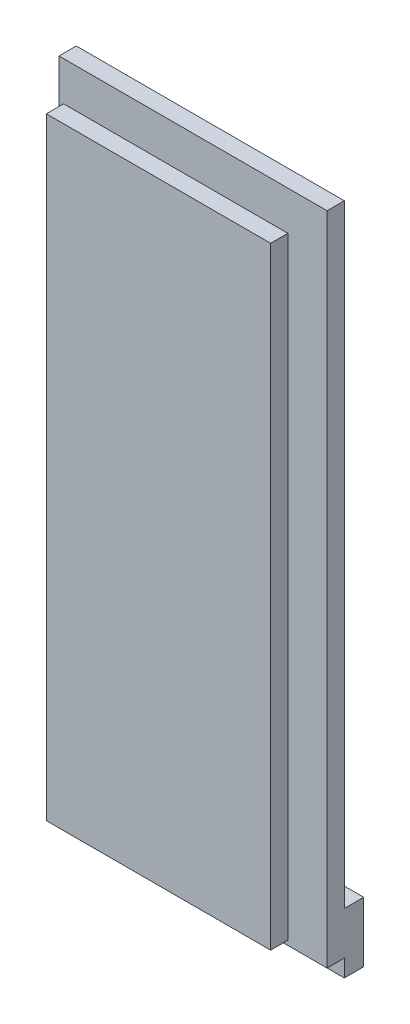
from build123d import *

# Parameters (mm, degrees)
SKETCH2_W      = 31.1404
SKETCH2_H      = 76.2
EXTRUDE1_DEPTH = 2.0066
SKETCH3_W      = 22.0472
SKETCH3_H      = 67.1068
EXTRUDE2_DEPTH = 2.0066
SKETCH4_W      = 26.0604
SKETCH4_H      = 71.12
EXTRUDE3_DEPTH = 2.0066
SKETCH5_W      = 31.1404
SKETCH5_H      = 7
EXTRUDE4_DEPTH = 2.25


with BuildPart() as part:
    # Sketch2 → Extrude1 (new body)
    with BuildSketch(Plane.XY):
        Rectangle(SKETCH2_W, SKETCH2_H)
    extrude(amount=EXTRUDE1_DEPTH)

    # Sketch3 → Extrude2 (add)
    with BuildSketch(Plane.XY.offset(2.0066)):
        Rectangle(SKETCH3_W, SKETCH3_H)
    extrude(amount=EXTRUDE2_DEPTH)

    # Sketch4 → Extrude3 (add)
    with BuildSketch(Plane.XY.offset(4.0132)):
        Rectangle(SKETCH4_W, SKETCH4_H)
    extrude(amount=EXTRUDE3_DEPTH)

    # Sketch5 → Extrude4 (add)
    with BuildSketch(Plane(origin=(0, 0, 0), x_dir=(-1, 0, 0), z_dir=(0, 0, -1))):
        with Locations((0, -36.6)):
            Rectangle(SKETCH5_W, SKETCH5_H)
    extrude(amount=EXTRUDE4_DEPTH)


solid = part.part
